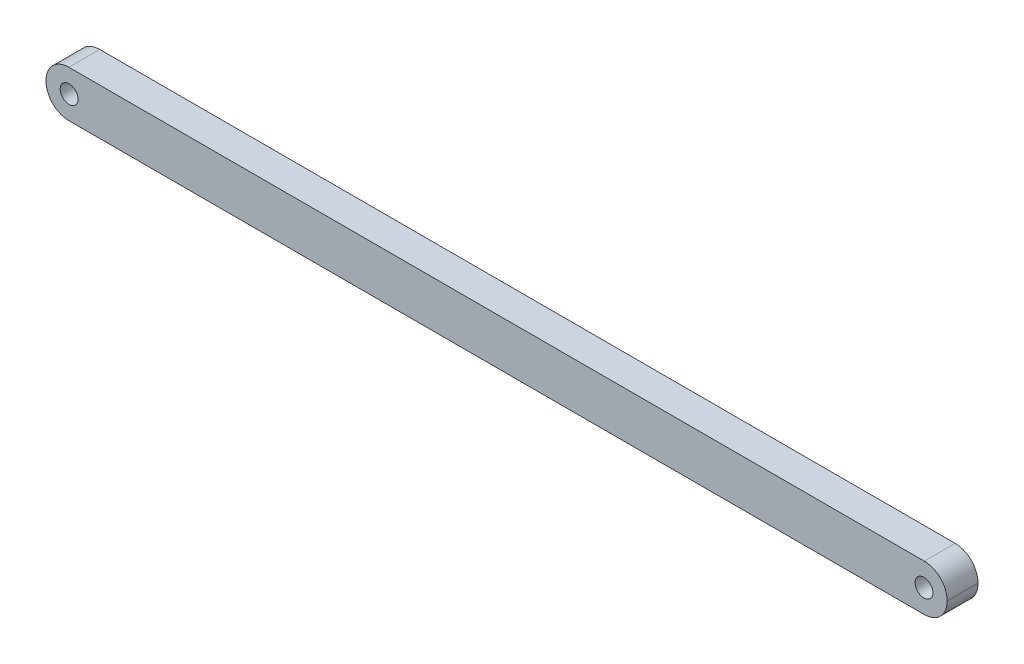
from build123d import *

# Parameters (mm, degrees)
SKETCH1_R           = 2.9
BOSS_EXTRUDE1_DEPTH = 10


with BuildPart() as part:
    # Sketch1 → Boss-Extrude1 (new body)
    with BuildSketch(Plane.XY):
        with BuildLine():
            Line((-138.65, -7.5), (138.65, -7.5))
            ThreePointArc((138.65, -7.5), (143.882590181, -5.332590181), (146.05, -0.1))
            Line((146.05, -0.1), (146.05, 0.1))
            ThreePointArc((146.05, 0.1), (143.882590181, 5.332590181), (138.65, 7.5))
            Line((138.65, 7.5), (-138.65, 7.5))
            ThreePointArc((-138.65, 7.5), (-143.882590181, 5.332590181), (-146.05, 0.1))
            Line((-146.05, 0.1), (-146.05, -0.1))
            ThreePointArc((-146.05, -0.1), (-143.882590181, -5.332590181), (-138.65, -7.5))
        make_face()
        with Locations((-138.55, 0)):
            Circle(SKETCH1_R, mode=Mode.SUBTRACT)
        with Locations((138.55, 0)):
            Circle(SKETCH1_R, mode=Mode.SUBTRACT)
    extrude(amount=BOSS_EXTRUDE1_DEPTH)


solid = part.part
